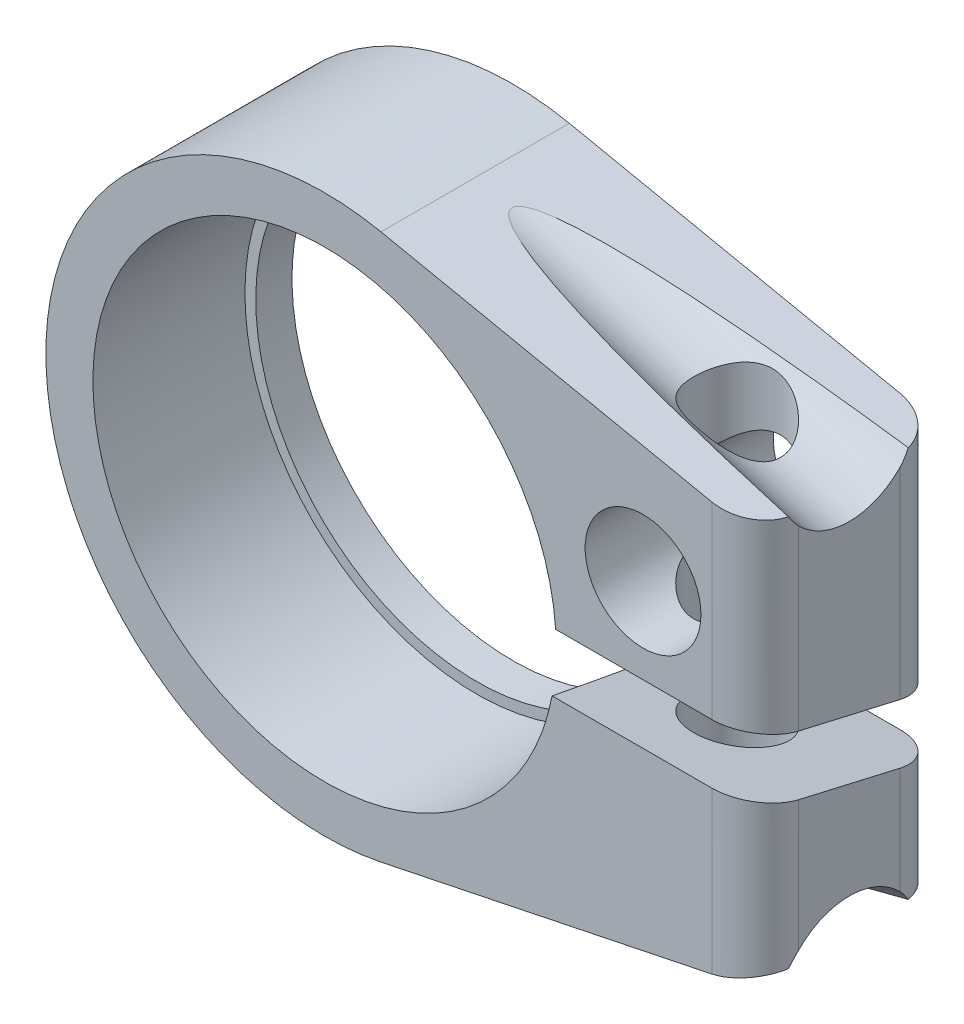
from build123d import *

# Parameters (mm, degrees)
ESQUISSE1_R                  = 15.25
EXTRUSION1_DEPTH             = 6.5
ESQUISSE2_R                  = 16
ENL_V_MAT_EXTRU_1_DEPTH      = 10.5
ENL_V_MAT_EXTRU_2_REACH      = 51
ESQUISSE4_R                  = 4
ENL_V_MAT_EXTRU_3_DEPTH      = 14
CONG_2_R                     = 3
ESQUISSE5_R                  = 3
ENL_V_MAT_EXTRU_4_DEPTH      = 20.25
ENL_V_MAT_EXTRU_4_DEPTH_BACK = 20.25
ENL_V_START                  = -10
ESQUISSE6_R                  = 4.5
ENL_V_MAT_EXTRU_5_DEPTH      = 10.25


with BuildPart() as part:
    # Esquisse1 → Extrusion1 (new body, symmetric)
    with BuildSketch(Plane.XY):
        with BuildLine():
            Line((3.901920053, 18.850398402), (29.75, 13.5))
            Line((29.75, 13.5), (29.75, -13.5))
            Line((29.75, -13.5), (3.901920053, -18.850398402))
            ThreePointArc((3.901920053, -18.850398402), (-19.25, 0), (3.901920053, 18.850398402))
        make_face()
        Circle(ESQUISSE1_R, mode=Mode.SUBTRACT)
    extrude(amount=EXTRUSION1_DEPTH, both=True)

    # Esquisse2 → Enlèv. mat.-Extru.1 (cut)
    with BuildSketch(Plane.XY.offset(6.5)):
        Circle(ESQUISSE2_R)
    extrude(amount=-ENL_V_MAT_EXTRU_1_DEPTH, mode=Mode.SUBTRACT)

    # Esquisse3 → Enlèv. mat.-Extru.2 (cut, up to next)
    with BuildSketch(Plane(origin=(29.75, 0, 0), x_dir=(0, 0, -1), z_dir=(1, 0, 0)), mode=Mode.PRIVATE) as enl_v_mat_extru_2_sk1:
        Polygon((6.5, -6), (-6.5, -2.998713515), (-6.5, 1.106502916), (6.5, -1.894783569), align=None)
    enl_v_mat_extru_2_tool1 = extrude(enl_v_mat_extru_2_sk1.sketch, amount=-ENL_V_MAT_EXTRU_2_REACH, mode=Mode.PRIVATE) & part.part
    add(enl_v_mat_extru_2_tool1.solids().sort_by_distance((29.75, -2.446749, 0))[0], mode=Mode.SUBTRACT)

    # Esquisse4 → Enlèv. mat.-Extru.3 (cut, through all)
    with BuildSketch(Plane.XY.offset(6.5)):
        with Locations((22, 7)):
            Circle(ESQUISSE4_R)
    extrude(amount=-ENL_V_MAT_EXTRU_3_DEPTH, mode=Mode.SUBTRACT)

    # Congé2
    cong_2_edges = [part.edges().sort_by_distance(p)[0] for p in [
        (29.75, -8.249356758, 6.5),
        (29.75, 5.802608216, -6.5),
        (29.75, 7.303251458, 6.5),
        (29.75, -9.75, -6.5),
    ]]
    fillet(cong_2_edges, radius=CONG_2_R)

    # Esquisse5 → Enlèv. mat.-Extru.4 (cut, two sides)
    with BuildSketch(Plane(origin=(0, 0, 0), x_dir=(1, 0, 0), z_dir=(0, 1, 0))) as enl_v_mat_extru_4_sk:
        with Locations(Location((22, 0, 0), (0, 0, 270))):  # turned: the seam where the file's is
            Circle(ESQUISSE5_R)
    extrude(amount=ENL_V_MAT_EXTRU_4_DEPTH, mode=Mode.SUBTRACT)
    extrude(enl_v_mat_extru_4_sk.sketch, amount=-ENL_V_MAT_EXTRU_4_DEPTH_BACK, mode=Mode.SUBTRACT)

    # Esquisse6 → Enlèv. mat.-Extru.5 (cut, through all)
    with BuildSketch(Plane(origin=(0, 0, 0), x_dir=(1, 0, 0), z_dir=(0, 1, 0)).offset(ENL_V_START)):
        with Locations(Location((22, 0, 0), (0, 0, 270))):  # turned: the seam where the file's is
            Circle(ESQUISSE6_R)
    extrude(amount=-ENL_V_MAT_EXTRU_5_DEPTH, mode=Mode.SUBTRACT)

    # Esquisse7 → Enlèvement de matière-Révolution1 (revolve, cut)
    with BuildSketch(Plane.XY):
        Polygon((7.917568964, -23.103302801), (6.45571044, -18.321779021), (29.75, -11.2), (31.211858524, -15.98152378), align=None)
    enl_vement_de_mati_re_r_volution1 = revolve(axis=Axis((-29.68487649, -34.599524074, 0), (0.956304756, 0.292371705, 0)), mode=Mode.SUBTRACT)

    # Symétrie1: Enlèvement de matière-Révolution1 across plane
    add(enl_vement_de_mati_re_r_volution1.mirror(Plane.ZX), mode=Mode.SUBTRACT)


solid = part.part
